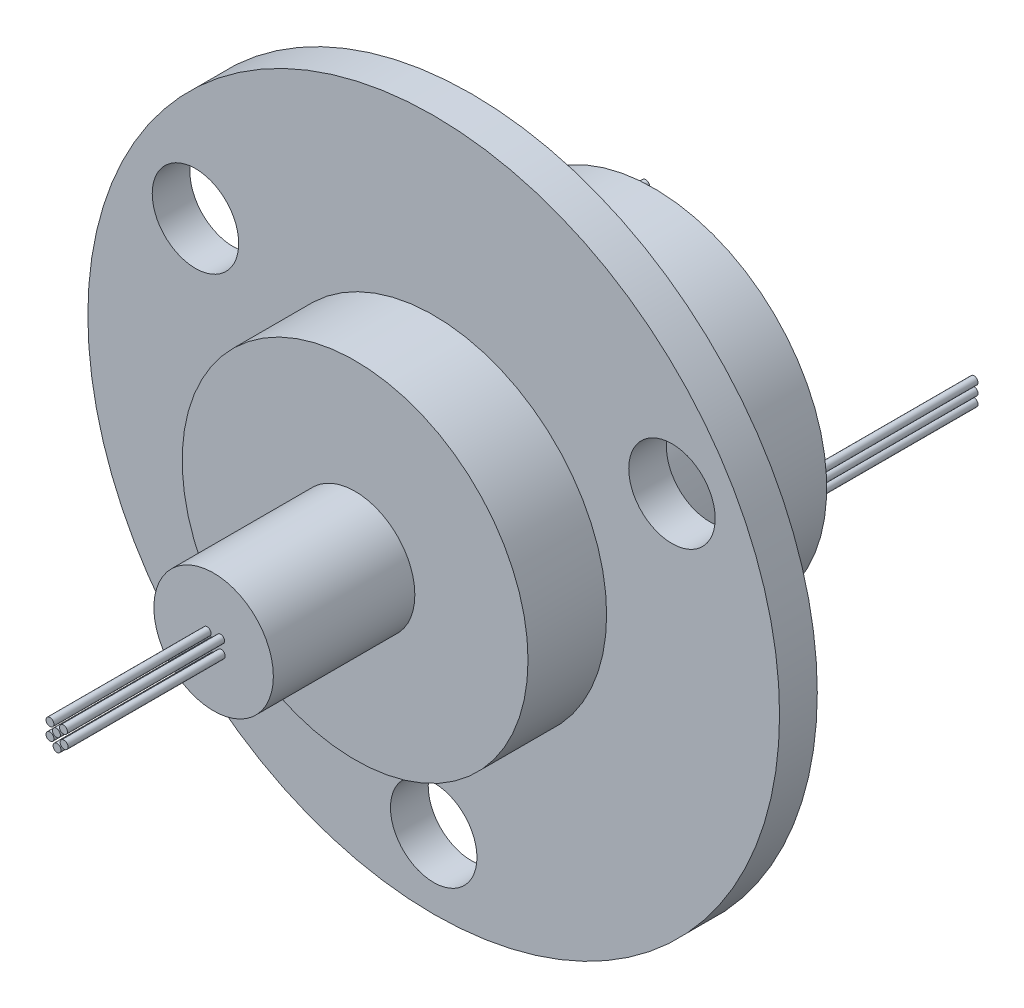
from build123d import *

# Parameters (mm, degrees)
SKETCH1_W                      = 22
SKETCH1_H                      = 2.4
SKETCH2_R                      = 11
BOSS_EXTRUDE1_DEPTH            = 5
SKETCH3_R                      = 3.8
BOSS_EXTRUDE2_DEPTH            = 9
SKETCH4_R                      = 0.25
BOSS_EXTRUDE3_DEPTH            = 10
SKETCH5_R                      = 11
BOSS_EXTRUDE4_DEPTH            = 11.6
SKETCH6_W                      = 0.25
SKETCH6_H                      = 10
SKETCH7_W                      = 0.25
SKETCH7_H                      = 10
SKETCH8_W                      = 0.25
SKETCH8_H                      = 10
SKETCH9_W                      = 0.25
SKETCH9_H                      = 10
SKETCH10_W                     = 0.25
SKETCH10_H                     = 10
SKETCH11_W                     = 0.25
SKETCH11_H                     = 10
SKETCH12_W                     = 0.25
SKETCH12_H                     = 10
SKETCH13_W                     = 0.25
SKETCH13_H                     = 10
SKETCH14_W                     = 0.25
SKETCH14_H                     = 10
SKETCH15_W                     = 0.25
SKETCH15_H                     = 10
SKETCH16_W                     = 0.25
SKETCH16_H                     = 10
F_5_5_5_5_DIAMETER_HOLE1_D     = 5.5
F_5_5_5_5_DIAMETER_HOLE1_DEPTH = 26.4


with BuildPart() as part:
    # Sketch1 → Revolve1 (revolve)
    with BuildSketch(Plane.XZ):
        with Locations((11, 1.2)):
            Rectangle(SKETCH1_W, SKETCH1_H)
    revolve(axis=Axis((0, 0, 2.4), (0, 0, -1)))

    # Sketch2 → Boss-Extrude1 (add)
    with BuildSketch(Plane.XY.offset(2.4)):
        Circle(SKETCH2_R)
    extrude(amount=BOSS_EXTRUDE1_DEPTH)

    # Sketch3 → Boss-Extrude2 (add)
    with BuildSketch(Plane.XY.offset(7.4)):
        Circle(SKETCH3_R)
    extrude(amount=BOSS_EXTRUDE2_DEPTH)

    # Sketch4 → Boss-Extrude3 (add)
    with BuildSketch(Plane.XY.offset(16.4)):
        Circle(SKETCH4_R)
    extrude(amount=BOSS_EXTRUDE3_DEPTH)

    # Sketch5 → Boss-Extrude4 (add)
    with BuildSketch(Plane(origin=(0, 0, 0), x_dir=(-1, 0, 0), z_dir=(0, 0, -1))):
        Circle(SKETCH5_R)
    extrude(amount=BOSS_EXTRUDE4_DEPTH)

    # Sketch6 → Revolve2 (revolve)
    with BuildSketch(Plane.XZ.offset(0.816347149)):
        with Locations((0.163253006, 21.4)):
            Rectangle(SKETCH6_W, SKETCH6_H)
    revolve(axis=Axis((0.038253006, -0.816347149, 26.4), (0, 0, -1)))

    # Sketch7 → Revolve3 (revolve)
    with BuildSketch(Plane.XZ.offset(0.416347149)):
        with Locations((0.613253006, 21.4)):
            Rectangle(SKETCH7_W, SKETCH7_H)
    revolve(axis=Axis((0.488253006, -0.416347149, 26.4), (0, 0, -1)))

    # Sketch8 → Revolve4 (revolve)
    with BuildSketch(Plane.XZ.offset(-0.383652851)):
        with Locations((-0.286746994, 21.4)):
            Rectangle(SKETCH8_W, SKETCH8_H)
    revolve(axis=Axis((-0.411746994, 0.383652851, 26.4), (0, 0, -1)))

    # Sketch9 → Revolve5 (revolve)
    with BuildSketch(Plane.XZ.offset(-0.400094572)):
        with Locations((0.572352369, 21.4)):
            Rectangle(SKETCH9_W, SKETCH9_H)
    revolve(axis=Axis((0.447352369, 0.400094572, 26.4), (0, 0, -1)))

    # Sketch10 → Revolve6 (revolve)
    with BuildSketch(Plane(origin=(0, -0.222432877, 0), x_dir=(1, 0, 0), z_dir=(0, 1, 0))):
        with Locations((-10.392433295, 16.6)):
            Rectangle(SKETCH10_W, SKETCH10_H)
    revolve(axis=Axis((-10.517433295, -0.222432877, -21.6), (0, 0, 1)))

    # Sketch11 → Revolve7 (revolve)
    with BuildSketch(Plane(origin=(0, 0.377567123, 0), x_dir=(1, 0, 0), z_dir=(0, 1, 0))):
        with Locations((-10.392433295, 16.6)):
            Rectangle(SKETCH11_W, SKETCH11_H)
    revolve(axis=Axis((-10.517433295, 0.377567123, -21.6), (0, 0, 1)))

    # Sketch12 → Revolve8 (revolve)
    with BuildSketch(Plane(origin=(0, 0.6, 0), x_dir=(1, 0, 0), z_dir=(0, 1, 0))):
        with Locations((10.496693215, 16.6)):
            Rectangle(SKETCH12_W, SKETCH12_H)
    revolve(axis=Axis((10.371693215, 0.6, -21.6), (0, 0, 1)))

    # Sketch13 → Revolve9 (revolve)
    with BuildSketch(Plane(origin=(0, 0, 0), x_dir=(1, 0, 0), z_dir=(0, 1, 0))):
        with Locations((10.496693215, 16.6)):
            Rectangle(SKETCH13_W, SKETCH13_H)
    revolve(axis=Axis((10.371693215, 0, -21.6), (0, 0, 1)))

    # Sketch14 → Revolve10 (revolve)
    with BuildSketch(Plane(origin=(0, -0.6, 0), x_dir=(1, 0, 0), z_dir=(0, 1, 0))):
        with Locations((10.496693215, 16.6)):
            Rectangle(SKETCH14_W, SKETCH14_H)
    revolve(axis=Axis((10.371693215, -0.6, -21.6), (0, 0, 1)))

    # Sketch15 → Revolve11 (revolve)
    with BuildSketch(Plane(origin=(0, 0.968647222, 0), x_dir=(1, 0, 0), z_dir=(0, 1, 0))):
        with Locations((-10.392433295, 16.6)):
            Rectangle(SKETCH15_W, SKETCH15_H)
    revolve(axis=Axis((-10.517433295, 0.968647222, -21.6), (0, 0, 1)))

    # Sketch16 → Revolve12 (revolve)
    with BuildSketch(Plane.XZ.offset(0.416347149)):
        with Locations((-0.286746994, 21.4)):
            Rectangle(SKETCH16_W, SKETCH16_H)
    revolve(axis=Axis((-0.411746994, -0.416347149, 26.4), (0, 0, -1)))

    # Ø5.5 (5.5) Diameter Hole1
    with Locations(Plane(origin=(0, 0, 0), x_dir=(-1, 0, 0), z_dir=(0, 0, -1))):
        with Locations((-15.155444566, 8.75), (15.155444566, 8.75), (0, -17.5)):
            Hole(F_5_5_5_5_DIAMETER_HOLE1_D / 2, depth=F_5_5_5_5_DIAMETER_HOLE1_DEPTH)


solid = part.part
